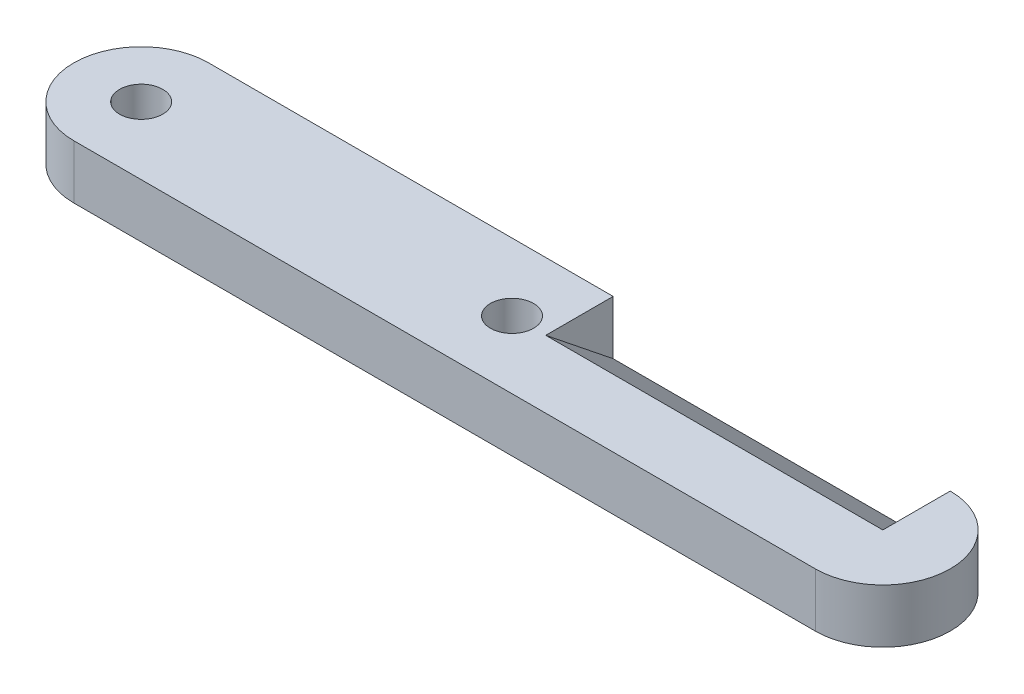
from build123d import *

# Parameters (mm, degrees)
BOSS_EXTRUDE1_DEPTH = 4
SKETCH2_R           = 1.6
CUT_EXTRUDE1_DEPTH  = 5
SKETCH3_W           = 25
SKETCH3_H           = 4
CUT_EXTRUDE2_DEPTH  = 5
BOSS_EXTRUDE2_DEPTH = 25


with BuildPart() as part:
    # Sketch1 → Boss-Extrude1 (new body)
    with BuildSketch(Plane(origin=(0, 0, 0), x_dir=(1, 0, 0), z_dir=(0, 1, 0))):
        with BuildLine():
            Line((0, 5), (55, 5))
            ThreePointArc((55, 5), (60, 0), (55, -5))
            Line((55, -5), (0, -5))
            ThreePointArc((0, -5), (-5, 0), (0, 5))
        make_face()
    extrude(amount=BOSS_EXTRUDE1_DEPTH)

    # Sketch2 → Cut-Extrude1 (cut, through all)
    with BuildSketch(Plane(origin=(0, 4, 0), x_dir=(1, 0, 0), z_dir=(0, 1, 0))):
        Circle(SKETCH2_R)
        with Locations((27.5, 0)):
            Circle(SKETCH2_R)
    extrude(amount=-CUT_EXTRUDE1_DEPTH, mode=Mode.SUBTRACT)

    # Sketch3 → Cut-Extrude2 (cut)
    with BuildSketch(Plane(origin=(0, 0, -5), x_dir=(-1, 0, 0), z_dir=(0, 0, -1))):
        with Locations((-42.5, 2)):
            Rectangle(SKETCH3_W, SKETCH3_H)
    extrude(amount=-CUT_EXTRUDE2_DEPTH, mode=Mode.SUBTRACT)

    # Sketch4 → Boss-Extrude2 (add)
    with BuildSketch(Plane.ZY.offset(-55)):
        Polygon((0, 4), (-5, 0), (0, 0), align=None)
    extrude(amount=BOSS_EXTRUDE2_DEPTH)


solid = part.part
